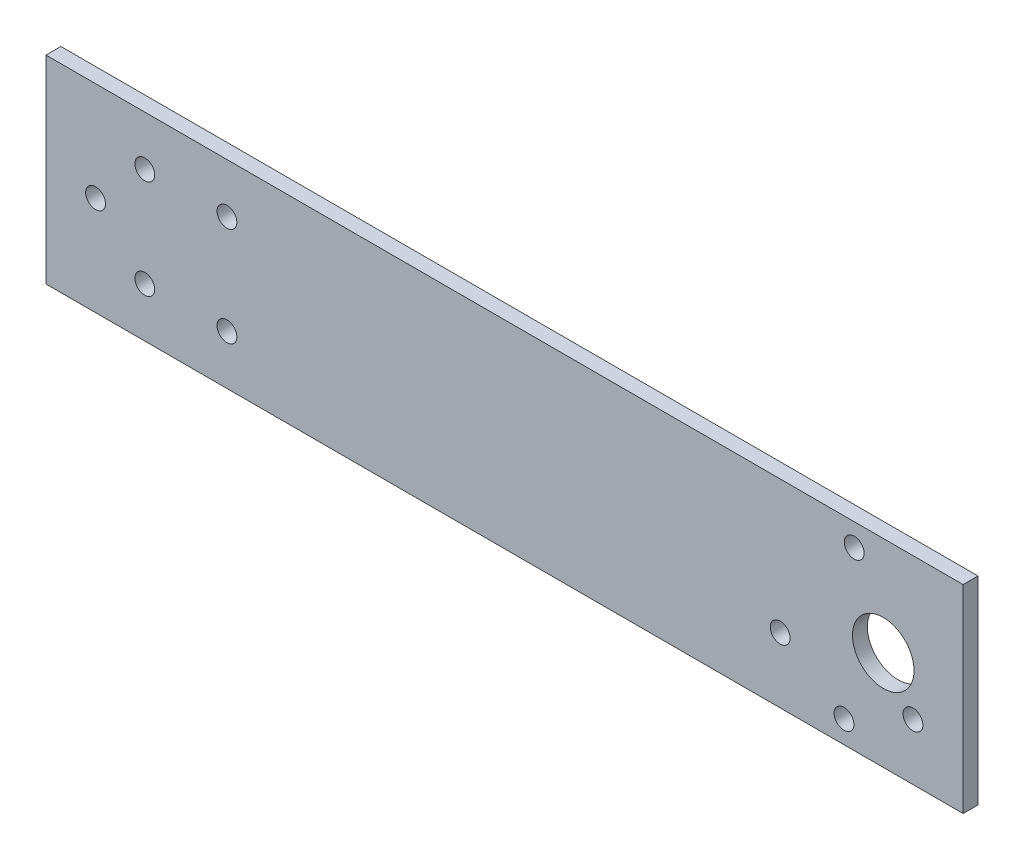
from build123d import *

# Parameters (mm, degrees)
SKETCH1_W           = 185
SKETCH1_H           = 40
SKETCH1_R           = 2
SKETCH1_R_2         = 6.20704278
BOSS_EXTRUDE1_DEPTH = 3


with BuildPart() as part:
    # Sketch1 → Boss-Extrude1 (new body)
    with BuildSketch(Plane.XY):
        with Locations((92.5, 20)):
            Rectangle(SKETCH1_W, SKETCH1_H)
        with Locations((36.5, 10)):
            Circle(SKETCH1_R, mode=Mode.SUBTRACT)
        with Locations((36.5, 30)):
            Circle(SKETCH1_R, mode=Mode.SUBTRACT)
        with Locations((168.884055736, 19.9999977)):
            Circle(SKETCH1_R_2, mode=Mode.SUBTRACT)
        with Locations((163.029062514, 35.465799332)):
            Circle(SKETCH1_R, mode=Mode.SUBTRACT)
        with Locations((174.879238376, 11.375898294)):
            Circle(SKETCH1_R, mode=Mode.SUBTRACT)
        with Locations((148.091684171, 13.158295477)):
            Circle(SKETCH1_R, mode=Mode.SUBTRACT)
        with Locations((160.970927527, 4.53419607)):
            Circle(SKETCH1_R, mode=Mode.SUBTRACT)
        with Locations((19.930250537, 30)):
            Circle(SKETCH1_R, mode=Mode.SUBTRACT)
        with Locations((19.930250537, 10)):
            Circle(SKETCH1_R, mode=Mode.SUBTRACT)
        with Locations((10, 20)):
            Circle(SKETCH1_R, mode=Mode.SUBTRACT)
    extrude(amount=BOSS_EXTRUDE1_DEPTH)


solid = part.part
